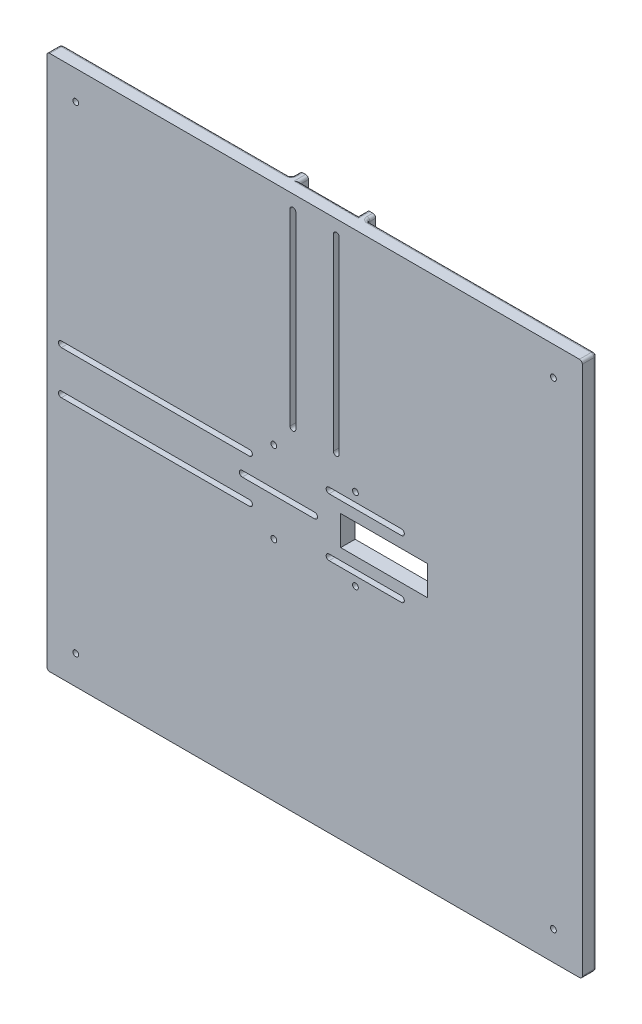
from build123d import *

# Parameters (mm, degrees)
ESQUISSE1_W              = 185
ESQUISSE1_H              = 185
BOSS_EXTRU_1_DEPTH       = 5
ESQUISSE2_W              = 70
ESQUISSE2_H              = 3
ESQUISSE2_W_2            = 3
ESQUISSE2_H_2            = 70
BOSS_EXTRU_2_DEPTH       = 3
CONG_1_R                 = 1
ENL_V_MAT_EXTRU_1_REACH  = 7
ESQUISSE4_R              = 1
ENL_V_MAT_EXTRU_2_DEPTH  = 6
ENL_V_MAT_EXTRU_3_REACH  = 7
ENL_V_MAT_EXTRU_5_REACH  = 10
ENL_V_MAT_EXTRU_7_REACH  = 7
ESQUISSE11_W             = 30
ESQUISSE11_H             = 10.2
ESQUISSE12_W             = 31
ESQUISSE12_H             = 4.2
ENL_V_MAT_EXTRU_9_DEPTH  = 2
CONG_2_R                 = 0.5
ENL_V_MAT_EXTRU_10_DEPTH = 2


with BuildPart() as part:
    # Esquisse1 → Boss.-Extru.1 (new body)
    with BuildSketch(Plane.XY):
        Rectangle(ESQUISSE1_W, ESQUISSE1_H)
    extrude(amount=BOSS_EXTRU_1_DEPTH)

    # Esquisse2 → Boss.-Extru.2 (add)
    with BuildSketch(Plane(origin=(0, 0, 0), x_dir=(-1, 0, 0), z_dir=(0, 0, -1))):
        with Locations((57.5, 11.6)):
            Rectangle(ESQUISSE2_W, ESQUISSE2_H)
        with Locations((57.5, -11.6)):
            Rectangle(ESQUISSE2_W, ESQUISSE2_H)
        with Locations((11.6, 57.5)):
            Rectangle(ESQUISSE2_W_2, ESQUISSE2_H_2)
        with Locations((-11.6, 57.5)):
            Rectangle(ESQUISSE2_W_2, ESQUISSE2_H_2)
    extrude(amount=BOSS_EXTRU_2_DEPTH)

    # Congé1
    cong_1_edges = [part.edges().sort_by_distance(p)[0] for p in [
        (0, 92.5, 0),
        (11.6, 22.5, 0),
        (13.1, 22.5, -1.5),
        (10.1, 92.5, -1.5),
        (13.1, 57.5, 0),
        (13.1, 92.5, -1.5),
        (-92.5, 0, 0),
        (-57.5, 13.1, 0),
        (-92.5, 13.1, -1.5),
        (-22.5, 11.6, 0),
        (-22.5, 13.1, -1.5),
        (-92.5, 10.1, -1.5),
        (-92.5, -52.8, 0),
        (-92.5, -13.1, -1.5),
        (-92.5, -10.1, -1.5),
        (-22.5, -11.6, 0),
        (-57.5, -13.1, 0),
        (-22.5, -13.1, -1.5),
        (-52.8, 92.5, 0),
        (-11.6, 22.5, 0),
        (-13.1, 57.5, 0),
        (-13.1, 22.5, -1.5),
        (-13.1, 92.5, -1.5),
        (-10.1, 92.5, -1.5),
        (52.8, 92.5, 0),
        (92.5, 0, 0),
        (0, -92.5, 0),
        (-92.5, 52.8, 0),
        (-92.5, 92.5, 2.5),
        (92.5, 92.5, 2.5),
        (92.5, -92.5, 2.5),
        (-92.5, -92.5, 2.5),
    ]]
    fillet(cong_1_edges, radius=CONG_1_R)

    # Esquisse4 → Enlèv. mat.-Extru.1 (cut, up to next)
    with BuildSketch(Plane(origin=(0, 0, 0), x_dir=(-1, 0, 0), z_dir=(0, 0, -1)), mode=Mode.PRIVATE) as enl_v_mat_extru_1_sk1:
        with Locations((-14.1, 14.1)):
            Circle(ESQUISSE4_R)
    enl_v_mat_extru_1_tool1 = extrude(enl_v_mat_extru_1_sk1.sketch, amount=-ENL_V_MAT_EXTRU_1_REACH, mode=Mode.PRIVATE) & part.part
    add(enl_v_mat_extru_1_tool1.solids().sort_by_distance((14.1, 14.1, 0))[0], mode=Mode.SUBTRACT)
    # Esquisse4 → Enlèv. mat.-Extru.1 (cut, up to next)
    with BuildSketch(Plane(origin=(0, 0, 0), x_dir=(-1, 0, 0), z_dir=(0, 0, -1)), mode=Mode.PRIVATE) as enl_v_mat_extru_1_sk2:
        with Locations((14.1, 14.1)):
            Circle(ESQUISSE4_R)
    enl_v_mat_extru_1_tool2 = extrude(enl_v_mat_extru_1_sk2.sketch, amount=-ENL_V_MAT_EXTRU_1_REACH, mode=Mode.PRIVATE) & part.part
    add(enl_v_mat_extru_1_tool2.solids().sort_by_distance((-14.1, 14.1, 0))[0], mode=Mode.SUBTRACT)
    # Esquisse4 → Enlèv. mat.-Extru.1 (cut, up to next)
    with BuildSketch(Plane(origin=(0, 0, 0), x_dir=(-1, 0, 0), z_dir=(0, 0, -1)), mode=Mode.PRIVATE) as enl_v_mat_extru_1_sk3:
        with Locations((14.1, -14.1)):
            Circle(ESQUISSE4_R)
    enl_v_mat_extru_1_tool3 = extrude(enl_v_mat_extru_1_sk3.sketch, amount=-ENL_V_MAT_EXTRU_1_REACH, mode=Mode.PRIVATE) & part.part
    add(enl_v_mat_extru_1_tool3.solids().sort_by_distance((-14.1, -14.1, 0))[0], mode=Mode.SUBTRACT)
    # Esquisse4 → Enlèv. mat.-Extru.1 (cut, up to next)
    with BuildSketch(Plane(origin=(0, 0, 0), x_dir=(-1, 0, 0), z_dir=(0, 0, -1)), mode=Mode.PRIVATE) as enl_v_mat_extru_1_sk4:
        with Locations((-14.1, -14.1)):
            Circle(ESQUISSE4_R)
    enl_v_mat_extru_1_tool4 = extrude(enl_v_mat_extru_1_sk4.sketch, amount=-ENL_V_MAT_EXTRU_1_REACH, mode=Mode.PRIVATE) & part.part
    add(enl_v_mat_extru_1_tool4.solids().sort_by_distance((14.1, -14.1, 0))[0], mode=Mode.SUBTRACT)
    # Esquisse4 → Enlèv. mat.-Extru.1 (cut, up to next)
    with BuildSketch(Plane(origin=(0, 0, 0), x_dir=(-1, 0, 0), z_dir=(0, 0, -1)), mode=Mode.PRIVATE) as enl_v_mat_extru_1_sk5:
        with Locations((-82.5, -82.5)):
            Circle(ESQUISSE4_R)
    enl_v_mat_extru_1_tool5 = extrude(enl_v_mat_extru_1_sk5.sketch, amount=-ENL_V_MAT_EXTRU_1_REACH, mode=Mode.PRIVATE) & part.part
    add(enl_v_mat_extru_1_tool5.solids().sort_by_distance((82.5, -82.5, 0))[0], mode=Mode.SUBTRACT)
    # Esquisse4 → Enlèv. mat.-Extru.1 (cut, up to next)
    with BuildSketch(Plane(origin=(0, 0, 0), x_dir=(-1, 0, 0), z_dir=(0, 0, -1)), mode=Mode.PRIVATE) as enl_v_mat_extru_1_sk6:
        with Locations((-82.5, 82.5)):
            Circle(ESQUISSE4_R)
    enl_v_mat_extru_1_tool6 = extrude(enl_v_mat_extru_1_sk6.sketch, amount=-ENL_V_MAT_EXTRU_1_REACH, mode=Mode.PRIVATE) & part.part
    add(enl_v_mat_extru_1_tool6.solids().sort_by_distance((82.5, 82.5, 0))[0], mode=Mode.SUBTRACT)
    # Esquisse4 → Enlèv. mat.-Extru.1 (cut, up to next)
    with BuildSketch(Plane(origin=(0, 0, 0), x_dir=(-1, 0, 0), z_dir=(0, 0, -1)), mode=Mode.PRIVATE) as enl_v_mat_extru_1_sk7:
        with Locations((82.5, -82.5)):
            Circle(ESQUISSE4_R)
    enl_v_mat_extru_1_tool7 = extrude(enl_v_mat_extru_1_sk7.sketch, amount=-ENL_V_MAT_EXTRU_1_REACH, mode=Mode.PRIVATE) & part.part
    add(enl_v_mat_extru_1_tool7.solids().sort_by_distance((-82.5, -82.5, 0))[0], mode=Mode.SUBTRACT)
    # Esquisse4 → Enlèv. mat.-Extru.1 (cut, up to next)
    with BuildSketch(Plane(origin=(0, 0, 0), x_dir=(-1, 0, 0), z_dir=(0, 0, -1)), mode=Mode.PRIVATE) as enl_v_mat_extru_1_sk8:
        with Locations((82.5, 82.5)):
            Circle(ESQUISSE4_R)
    enl_v_mat_extru_1_tool8 = extrude(enl_v_mat_extru_1_sk8.sketch, amount=-ENL_V_MAT_EXTRU_1_REACH, mode=Mode.PRIVATE) & part.part
    add(enl_v_mat_extru_1_tool8.solids().sort_by_distance((-82.5, 82.5, 0))[0], mode=Mode.SUBTRACT)

    # Esquisse5 → Enlèv. mat.-Extru.2 (cut, through all)
    with BuildSketch(Plane(origin=(0, 0, 0), x_dir=(-1, 0, 0), z_dir=(0, 0, -1))):
        with BuildLine():
            Line((-6.5, 87.5), (-6.5, 22.5))
            ThreePointArc((-6.5, 22.5), (-7.5, 21.5), (-8.5, 22.5))
            Line((-8.5, 22.5), (-8.5, 87.5))
            ThreePointArc((-8.5, 87.5), (-7.5, 88.5), (-6.5, 87.5))
        make_face()
        with BuildLine():
            Line((8.5, 87.5), (8.5, 22.5))
            ThreePointArc((8.5, 22.5), (7.5, 21.5), (6.5, 22.5))
            Line((6.5, 22.5), (6.5, 87.5))
            ThreePointArc((6.5, 87.5), (7.5, 88.5), (8.5, 87.5))
        make_face()
    extrude(amount=-ENL_V_MAT_EXTRU_2_DEPTH, mode=Mode.SUBTRACT)

    # Esquisse6 → Enlèv. mat.-Extru.3 (cut, up to next)
    with BuildSketch(Plane(origin=(0, 0, 0), x_dir=(-1, 0, 0), z_dir=(0, 0, -1)), mode=Mode.PRIVATE) as enl_v_mat_extru_3_sk1:
        with BuildLine():
            Line((87.5, -8.5), (22.5, -8.5))
            ThreePointArc((22.5, -8.5), (21.5, -7.5), (22.5, -6.5))
            Line((22.5, -6.5), (87.5, -6.5))
            ThreePointArc((87.5, -6.5), (88.5, -7.5), (87.5, -8.5))
        make_face()
    enl_v_mat_extru_3_tool1 = extrude(enl_v_mat_extru_3_sk1.sketch, amount=-ENL_V_MAT_EXTRU_3_REACH, mode=Mode.PRIVATE) & part.part
    add(enl_v_mat_extru_3_tool1.solids().sort_by_distance((-55, -7.5, 0))[0], mode=Mode.SUBTRACT)
    # Esquisse6 → Enlèv. mat.-Extru.3 (cut, up to next)
    with BuildSketch(Plane(origin=(0, 0, 0), x_dir=(-1, 0, 0), z_dir=(0, 0, -1)), mode=Mode.PRIVATE) as enl_v_mat_extru_3_sk2:
        with BuildLine():
            Line((22.5, 8.5), (87.5, 8.5))
            ThreePointArc((87.5, 8.5), (88.5, 7.5), (87.5, 6.5))
            Line((87.5, 6.5), (22.5, 6.5))
            ThreePointArc((22.5, 6.5), (21.5, 7.5), (22.5, 8.5))
        make_face()
    enl_v_mat_extru_3_tool2 = extrude(enl_v_mat_extru_3_sk2.sketch, amount=-ENL_V_MAT_EXTRU_3_REACH, mode=Mode.PRIVATE) & part.part
    add(enl_v_mat_extru_3_tool2.solids().sort_by_distance((-55, 7.5, 0))[0], mode=Mode.SUBTRACT)

    # Esquisse9 → Enlèv. mat.-Extru.5 (cut, up to next)
    with BuildSketch(Plane.XY.offset(5), mode=Mode.PRIVATE) as enl_v_mat_extru_5_sk1:
        with BuildLine():
            Line((-25, 1), (0, 1))
            ThreePointArc((0, 1), (1, 0), (0, -1))
            Line((0, -1), (-25, -1))
            ThreePointArc((-25, -1), (-26, 0), (-25, 1))
        make_face()
    enl_v_mat_extru_5_tool1 = extrude(enl_v_mat_extru_5_sk1.sketch, amount=-ENL_V_MAT_EXTRU_5_REACH, mode=Mode.PRIVATE) & part.part
    add(enl_v_mat_extru_5_tool1.solids().sort_by_distance((-12.5, 0, 5))[0], mode=Mode.SUBTRACT)
    # Esquisse9 → Enlèv. mat.-Extru.5 (cut, up to next)
    with BuildSketch(Plane.XY.offset(5), mode=Mode.PRIVATE) as enl_v_mat_extru_5_sk2:
        with BuildLine():
            Line((5, 11), (30, 11))
            ThreePointArc((30, 11), (31, 10), (30, 9))
            Line((30, 9), (5, 9))
            ThreePointArc((5, 9), (4, 10), (5, 11))
        make_face()
    enl_v_mat_extru_5_tool2 = extrude(enl_v_mat_extru_5_sk2.sketch, amount=-ENL_V_MAT_EXTRU_5_REACH, mode=Mode.PRIVATE) & part.part
    add(enl_v_mat_extru_5_tool2.solids().sort_by_distance((17.5, 10, 5))[0], mode=Mode.SUBTRACT)
    # Esquisse9 → Enlèv. mat.-Extru.5 (cut, up to next)
    with BuildSketch(Plane.XY.offset(5), mode=Mode.PRIVATE) as enl_v_mat_extru_5_sk3:
        with BuildLine():
            Line((5, -9), (30, -9))
            ThreePointArc((30, -9), (31, -10), (30, -11))
            Line((30, -11), (5, -11))
            ThreePointArc((5, -11), (4, -10), (5, -9))
        make_face()
    enl_v_mat_extru_5_tool3 = extrude(enl_v_mat_extru_5_sk3.sketch, amount=-ENL_V_MAT_EXTRU_5_REACH, mode=Mode.PRIVATE) & part.part
    add(enl_v_mat_extru_5_tool3.solids().sort_by_distance((17.5, -10, 5))[0], mode=Mode.SUBTRACT)

    # Esquisse11 → Enlèv. mat.-Extru.7 (cut, up to next)
    with BuildSketch(Plane(origin=(0, 0, 0), x_dir=(-1, 0, 0), z_dir=(0, 0, -1)), mode=Mode.PRIVATE) as enl_v_mat_extru_7_sk1:
        with Locations((-24, 0)):
            Rectangle(ESQUISSE11_W, ESQUISSE11_H)
    enl_v_mat_extru_7_tool1 = extrude(enl_v_mat_extru_7_sk1.sketch, amount=-ENL_V_MAT_EXTRU_7_REACH, mode=Mode.PRIVATE) & part.part
    add(enl_v_mat_extru_7_tool1.solids().sort_by_distance((24, 0, 0))[0], mode=Mode.SUBTRACT)

    # Esquisse12 → Enlèv. mat.-Extru.9 (cut)
    with BuildSketch(Plane(origin=(0, 0, 0), x_dir=(-1, 0, 0), z_dir=(0, 0, -1))):
        with Locations((-17.5, 10)):
            Rectangle(ESQUISSE12_W, ESQUISSE12_H)
        with Locations((-17.5, -10)):
            Rectangle(ESQUISSE12_W, ESQUISSE12_H)
        with Locations((12.5, 0)):
            Rectangle(ESQUISSE12_W, ESQUISSE12_H)
    extrude(amount=-ENL_V_MAT_EXTRU_9_DEPTH, mode=Mode.SUBTRACT)

    # Congé2
    cong_2_edges = [part.edges().sort_by_distance(p)[0] for p in [
        (33, 7.9, 1),
        (33, 12.1, 1),
        (2, 12.1, 1),
        (33, -12.1, 1),
        (33, -7.9, 1),
        (2, -7.9, 1),
        (2, -12.1, 1),
        (3, -2.1, 1),
        (3, 2.1, 1),
        (-28, 2.1, 1),
        (-28, -2.1, 1),
    ]]
    fillet(cong_2_edges, radius=CONG_2_R)

    # Esquisse13 → Enlèv. mat.-Extru.10 (cut)
    with BuildSketch(Plane(origin=(0, 0, 0), x_dir=(-1, 0, 0), z_dir=(0, 0, -1))):
        Polygon((-80.17, -82.5), (-81.335, -80.482160809), (-83.665, -80.482160809), (-84.83, -82.5), (-83.665, -84.517839191), (-81.335, -84.517839191), align=None)
        Polygon((83.665, -84.517839191), (84.83, -82.5), (83.665, -80.482160809), (81.335, -80.482160809), (80.17, -82.5), (81.335, -84.517839191), align=None)
        Polygon((84.83, 82.5), (83.665, 84.517839191), (81.335, 84.517839191), (80.17, 82.5), (81.335, 80.482160809), (83.665, 80.482160809), align=None)
        Polygon((-80.17, 82.5), (-81.335, 84.517839191), (-83.665, 84.517839191), (-84.83, 82.5), (-83.665, 80.482160809), (-81.335, 80.482160809), align=None)
    extrude(amount=-ENL_V_MAT_EXTRU_10_DEPTH, mode=Mode.SUBTRACT)


solid = part.part
